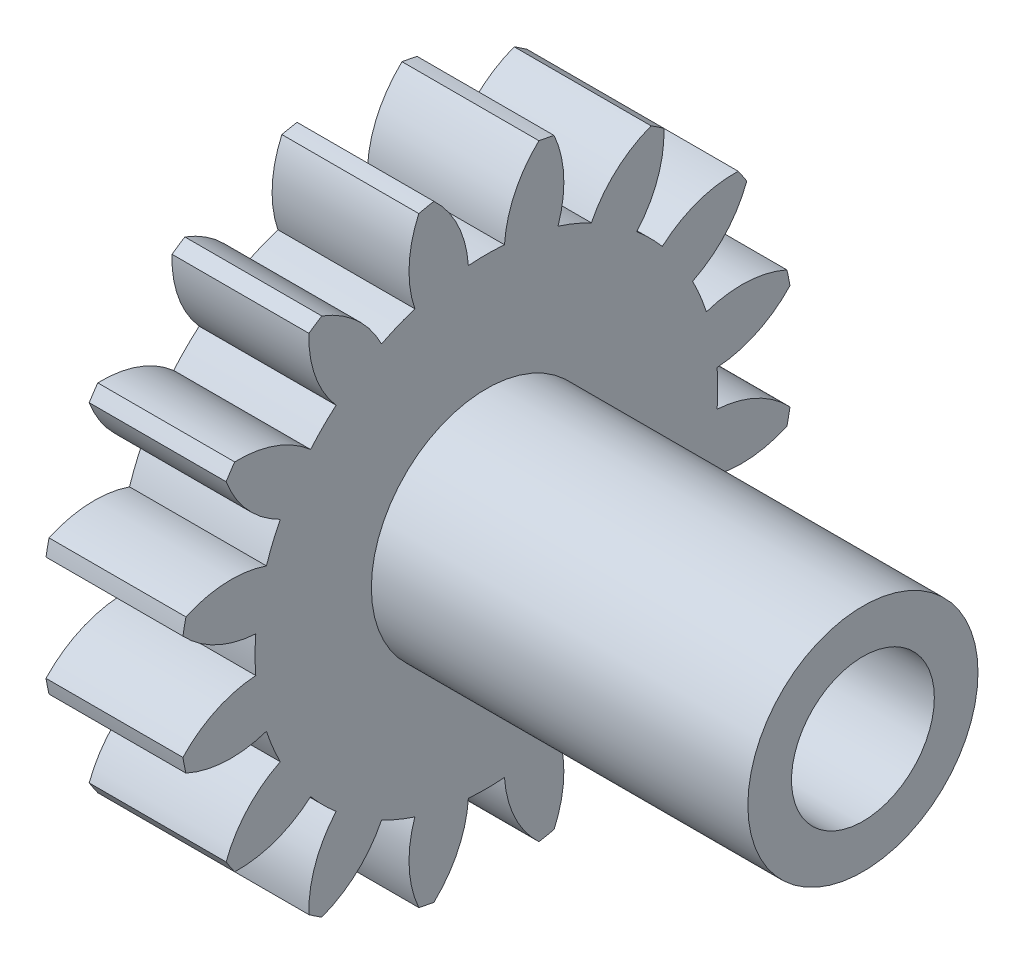
from build123d import *

# Parameters (mm, degrees)
BASPROSKE_W         = 5.08
BASPROSKE_H         = 11.43
TOOTHCUT_DEPTH      = 17.943913361
TEETHCUTS_COUNT     = 16
TEETHCUTS_ANGLE     = 337.5
BORSKE_R            = 0.99949
BORE_DEPTH          = 50.8000508
SKETCH1_R           = 0.99949
BOSS_EXTRUDE1_DEPTH = 5.08
SKETCH2_R           = 4.269999969
BOSS_EXTRUDE2_DEPTH = 13.97
SKETCH3_R           = 2.65
CUT_EXTRUDE1_DEPTH  = 3.81


with BuildPart() as part:
    # BasProSke → Base-Revolve (revolve)
    with BuildSketch(Plane(origin=(0, 0, 0), x_dir=(1, 0, 0), z_dir=(0, 1, 0)), mode=Mode.PRIVATE) as base_revolve_sk:
        with Locations((2.54, 5.715)):
            Rectangle(BASPROSKE_W, BASPROSKE_H)
    revolve(base_revolve_sk.sketch.rotate(Axis((-10, 0, 0), (1, 0, 0)), 180), axis=Axis((-10, 0, 0), (1, 0, 0)))

    # TooCutSke → ToothCut (cut, through all)
    with BuildSketch(Plane(origin=(0, 0, 0), x_dir=(0, 0, -1), z_dir=(1, 0, 0))):
        with BuildLine():
            ThreePointArc((0.669851294, 8.559027882), (0, 8.5852), (-0.669851294, 8.559027882))
            ThreePointArc((-0.669851294, 8.559027882), (-1.058014649, 10.047160022), (-1.971359535, 11.284499579))
            ThreePointArc((-1.971359535, 11.284499579), (0, 11.4554), (1.971359535, 11.284499579))
            ThreePointArc((1.971359535, 11.284499579), (1.058014649, 10.047160022), (0.669851294, 8.559027882))
        make_face()
    toothcut = extrude(amount=TOOTHCUT_DEPTH, mode=Mode.SUBTRACT)

    # TeethCuts: ToothCut ×16 about axis
    teethcuts_axis = Axis((-10, 0, 0), (1, 0, 0))
    for i in range(1, TEETHCUTS_COUNT):
        add(toothcut.rotate(teethcuts_axis, i * TEETHCUTS_ANGLE / (TEETHCUTS_COUNT - 1)), mode=Mode.SUBTRACT)

    # BorSke → Bore (cut, symmetric)
    with BuildSketch(Plane(origin=(0, 0, 0), x_dir=(0, 0, -1), z_dir=(1, 0, 0))):
        with Locations(Location((0, 0, 0), (0, 0, 180))):
            Circle(BORSKE_R)
    extrude(amount=BORE_DEPTH, both=True, mode=Mode.SUBTRACT)

    # Sketch1 → Boss-Extrude1 (add)
    with BuildSketch(Plane(origin=(5.08, 0, 0), x_dir=(0, 0, -1), z_dir=(1, 0, 0))):
        Circle(SKETCH1_R)
    extrude(amount=-BOSS_EXTRUDE1_DEPTH)

    # Sketch2 → Boss-Extrude2 (add)
    with BuildSketch(Plane(origin=(5.08, 0, 0), x_dir=(0, 0, -1), z_dir=(1, 0, 0))):
        with Locations(Location((0, 0, 0), (0, 0, 180))):
            Circle(SKETCH2_R)
    extrude(amount=BOSS_EXTRUDE2_DEPTH)

    # Sketch3 → Cut-Extrude1 (cut)
    with BuildSketch(Plane(origin=(19.05, 0, 0), x_dir=(0, 0, -1), z_dir=(1, 0, 0))):
        Circle(SKETCH3_R)
    extrude(amount=-CUT_EXTRUDE1_DEPTH, mode=Mode.SUBTRACT)


solid = part.part
